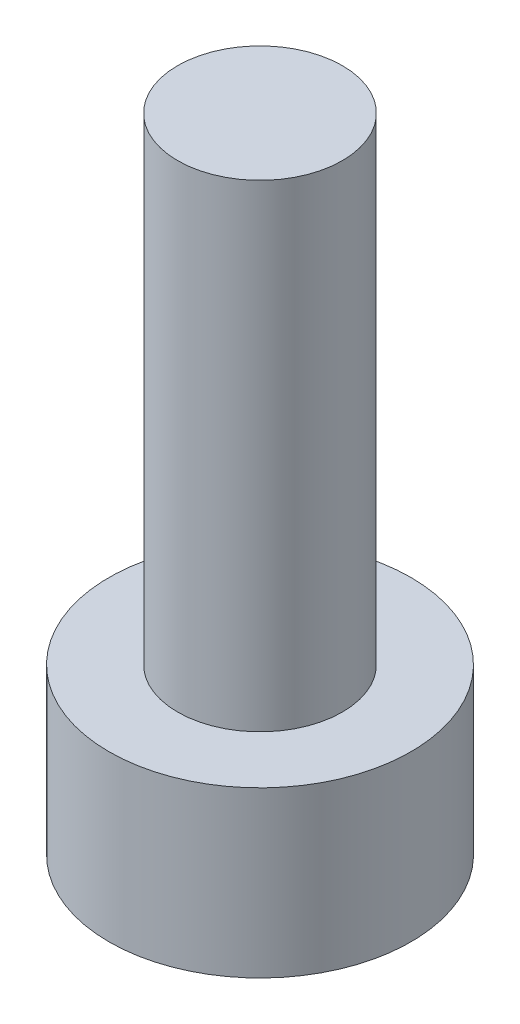
from build123d import *

# Parameters (mm, degrees)
SKETCH1_R           = 2.75
BOSS_EXTRUDE1_DEPTH = 3
SKETCH2_R           = 1.5
BOSS_EXTRUDE2_DEPTH = 8.7


with BuildPart() as part:
    # Sketch1 → Boss-Extrude1 (new body)
    with BuildSketch(Plane(origin=(0, 0, 0), x_dir=(1, 0, 0), z_dir=(0, 1, 0))):
        Circle(SKETCH1_R)
    extrude(amount=BOSS_EXTRUDE1_DEPTH)

    # Sketch2 → Boss-Extrude2 (add)
    with BuildSketch(Plane(origin=(0, 3, 0), x_dir=(1, 0, 0), z_dir=(0, 1, 0))):
        Circle(SKETCH2_R)
    extrude(amount=BOSS_EXTRUDE2_DEPTH)


solid = part.part
